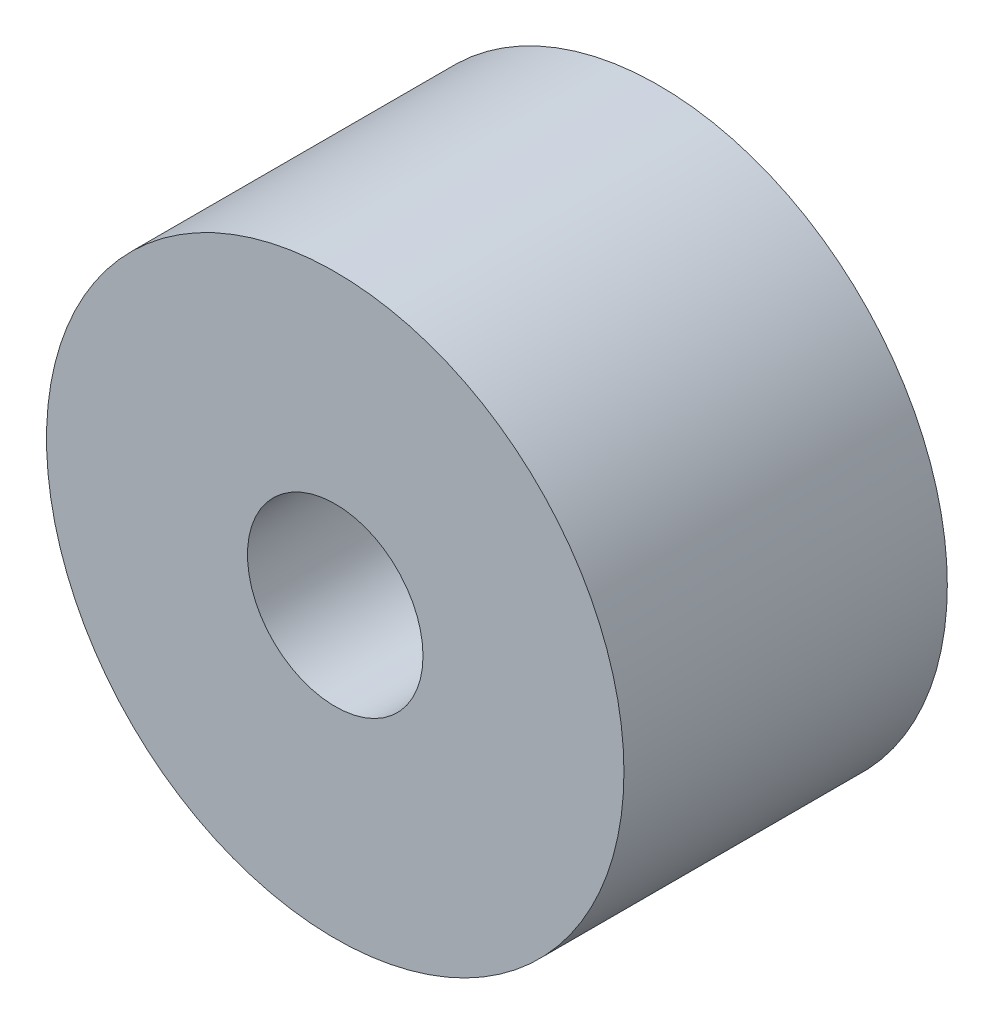
from build123d import *

# Parameters (mm, degrees)
SKETCH1_R           = 62.5
SKETCH1_R_2         = 19
BOSS_EXTRUDE1_DEPTH = 70


with BuildPart() as part:
    # Sketch1 → Boss-Extrude1 (new body)
    with BuildSketch(Plane.XY):
        Circle(SKETCH1_R)
        Circle(SKETCH1_R_2, mode=Mode.SUBTRACT)
    extrude(amount=BOSS_EXTRUDE1_DEPTH)


solid = part.part
